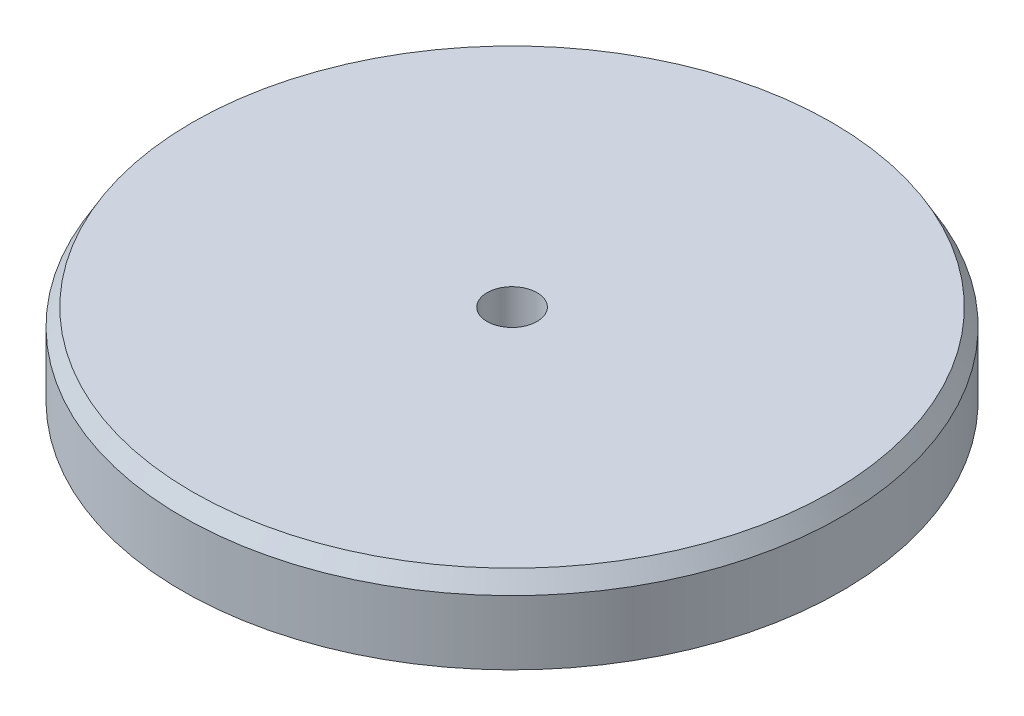
from build123d import *

# Parameters (mm, degrees)
CHAMFER1_SIZE  = 0.381
CHAMFER1_SIZE2 = 0.659911358


with BuildPart() as part:
    # Sketch1 → Revolve1 (revolve)
    with BuildSketch(Plane(origin=(0, 0, 0), x_dir=(0, 0, -1), z_dir=(1, 0, 0))):
        with BuildLine():
            Line((-0.9779, 0), (-0.9779, 7.62))
            Line((-0.9779, 7.62), (-12.8905, 7.62))
            Line((-12.8905, 7.62), (-12.8905, 4.445))
            Line((-12.8905, 4.445), (-7.62, 4.445))
            ThreePointArc((-7.62, 4.445), (-5.823948776, 3.701051224), (-5.08, 1.905))
            Line((-5.08, 1.905), (-5.08, 0))
            Line((-5.08, 0), (-0.9779, 0))
        make_face()
    revolve(axis=Axis((0, 0, 0), (0, 1, 0)))

    # Chamfer1
    chamfer1_edges = [part.edges().sort_by_distance(p)[0] for p in [
        (0, 7.62, -12.8905),
    ]]
    chamfer1_side = [part.faces().sort_by_distance(p)[0] for p in [
        (0, 7.62, -1.342498399),
    ]]
    chamfer(chamfer1_edges, length=CHAMFER1_SIZE, length2=CHAMFER1_SIZE2, reference=chamfer1_side[0])


solid = part.part
